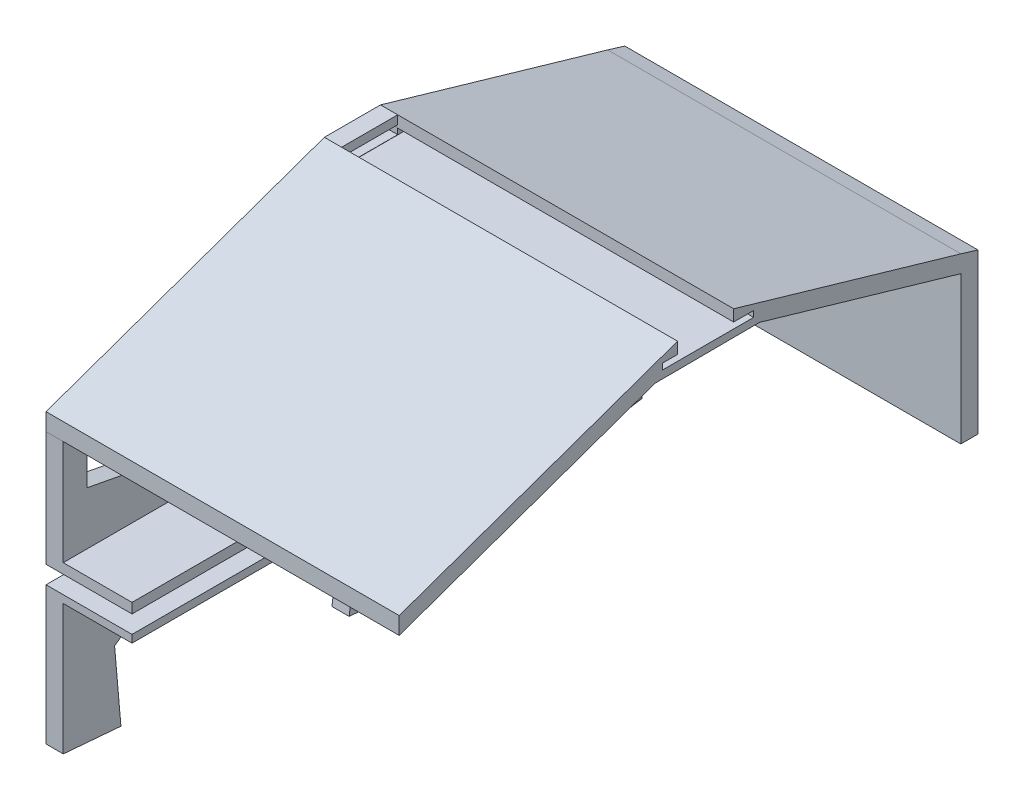
from build123d import *

# Parameters (mm, degrees)
SKETCH1_W           = 20.735936364
SKETCH1_H           = 3.175
BOSS_EXTRUDE1_DEPTH = 6.35
SKETCH2_W           = 82.651107169
SKETCH2_H           = 6.52720724
SKETCH2_W_2         = 76.969823319
SKETCH2_H_2         = 6.604
CUT_EXTRUDE1_DEPTH  = 7.35
SKETCH6_W           = 206.502
SKETCH6_H           = 3.711703494
SKETCH6_H_2         = 2.816288331
BOSS_EXTRUDE3_DEPTH = 31.75
BOSS_EXTRUDE5_DEPTH = 130.429


with BuildPart() as part:
    # Sketch1 → Boss-Extrude1 (new body)
    with BuildSketch(Plane(origin=(0, 0, 0), x_dir=(0, 0, -1), z_dir=(1, 0, 0))):
        Polygon((-123.525645009, 81.218983384), (-123.525645009, -25.082949612), (-102.22101814, -26.860004783), (-104.557017494, 0), (-79.646789796, 17.686261666), (-41.094549164, 17.686261666), (-13.779824281, -3.641289166), (-17.947471695, -33.889404663), (-12.561862574, -34.338627482), (90.228248196, -18.303088648), (90.228248196, 91.281577209), (0, 117.577378193), (-20.735936364, 117.577378193), align=None)
        Polygon((5.201841666, 40.001048477), (77.528248196, 55.056292197), (77.528248196, 85.830387495), (5.201841666, 105.015188817), align=None, mode=Mode.SUBTRACT)
        Polygon((-79.646789796, 84.224142025), (-79.646789796, 48.574048336), (0, 40.007327233), (0, 105.015188817), (-20.735936364, 105.015188817), align=None, mode=Mode.SUBTRACT)
        Polygon((-86.090479579, 81.218983384), (-86.090479579, 50.197772081), (-114.759972161, 55.666680192), (-114.759972161, 71.350976637), align=None, mode=Mode.SUBTRACT)
        with Locations((-10.367968182, 112.814878193)):
            Rectangle(SKETCH1_W, SKETCH1_H, mode=Mode.SUBTRACT)
    extrude(amount=BOSS_EXTRUDE1_DEPTH)

    # Sketch2 → Cut-Extrude1 (cut, through all)
    with BuildSketch(Plane(origin=(6.35, 0, 0), x_dir=(0, 0, -1), z_dir=(1, 0, 0))):
        with Locations((117.850801407, 29.125465717)):
            Rectangle(SKETCH2_W, SKETCH2_H)
        with Locations((-85.04073335, 29.163862097)):
            Rectangle(SKETCH2_W_2, SKETCH2_H_2)
    extrude(amount=-CUT_EXTRUDE1_DEPTH, mode=Mode.SUBTRACT)

    # Sketch6 → Boss-Extrude3 (add)
    with BuildSketch(Plane.ZY):
        with Locations((20.274645009, 34.244921084)):
            Rectangle(SKETCH6_W, SKETCH6_H)
        with Locations((20.274645009, 24.453717932)):
            Rectangle(SKETCH6_W, SKETCH6_H_2)
    extrude(amount=-BOSS_EXTRUDE3_DEPTH)

    # Sketch8 → Boss-Extrude5 (add)
    with BuildSketch(Plane.ZY):
        Polygon((0, 117.577378193), (-83.878248196, 93.218298083), (-90.228248196, 91.281577209), (-90.228248196, 32.389069337), (-83.878248196, 32.389069337), (-83.878248196, 86.868298083), (-9.525197863, 108.461165703), (29.097772116, 108.270149457), (123.542635704, 74.868983384), (123.525645009, 81.218983384), (20.735936364, 117.577378193), (20.752927059, 113.344232588), (26.228286967, 113.344232588), (26.228286967, 111.139694939), (20.752927059, 111.139694939), (0.016990695, 111.139694939), (-7.377605414, 111.139694939), (-7.377605414, 113.344232588), (0.011172356, 113.344232588), align=None)
    extrude(amount=-BOSS_EXTRUDE5_DEPTH)


solid = part.part
